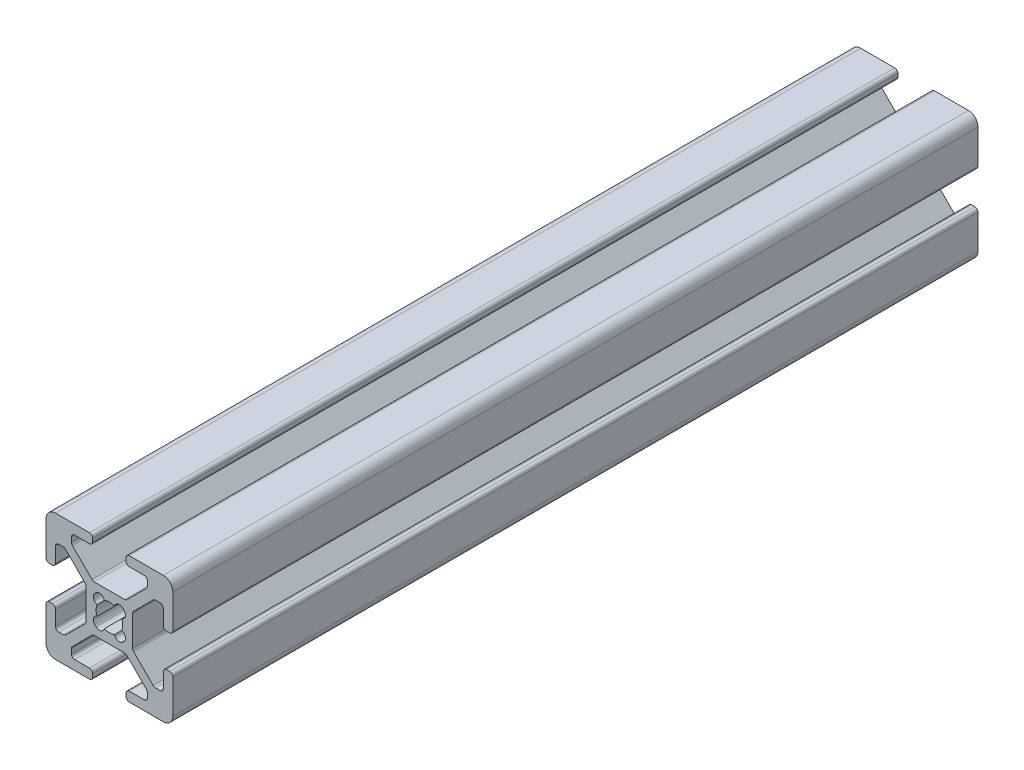
from build123d import *

# Parameters (mm, degrees)
BOSS_EXTRUDE1_DEPTH = 127


with BuildPart() as part:
    # Sketch1 → Boss-Extrude1 (new body)
    with BuildSketch(Plane(origin=(0, 0, -4000), x_dir=(-1, 0, 0), z_dir=(0, 0, -1))):
        with BuildLine():
            Line((10, -8.5), (10, -3.138))
            ThreePointArc((10, -3.138), (9.851210245, -2.778789755), (9.492, -2.63))
            Line((9.492, -2.63), (9.008, -2.63))
            ThreePointArc((9.008, -2.63), (8.648789755, -2.778789755), (8.5, -3.138))
            Line((8.5, -3.138), (8.5, -5.487))
            ThreePointArc((8.5, -5.487), (8.351210245, -5.846210245), (7.992, -5.995))
            Line((7.992, -5.995), (7.26592049, -5.995))
            ThreePointArc((7.26592049, -5.995), (7.071517306, -5.956330803), (6.906710245, -5.846210245))
            Line((6.906710245, -5.846210245), (3.803789755, -2.743289755))
            ThreePointArc((3.803789755, -2.743289755), (3.693669197, -2.578482694), (3.655, -2.38407951))
            Line((3.655, -2.38407951), (3.655, 2.383759167))
            ThreePointArc((3.655, 2.383759167), (3.693669197, 2.57816235), (3.803789755, 2.742969412))
            Line((3.803789755, 2.742969412), (6.907030588, 5.846210245))
            ThreePointArc((6.907030588, 5.846210245), (7.07183765, 5.956330803), (7.266240833, 5.995))
            Line((7.266240833, 5.995), (7.992, 5.995))
            ThreePointArc((7.992, 5.995), (8.351210245, 5.846210245), (8.5, 5.487))
            Line((8.5, 5.487), (8.5, 3.138))
            ThreePointArc((8.5, 3.138), (8.648789755, 2.778789755), (9.008, 2.63))
            Line((9.008, 2.63), (9.492, 2.63))
            ThreePointArc((9.492, 2.63), (9.851210245, 2.778789755), (10, 3.138))
            Line((10, 3.138), (10, 8.5))
            ThreePointArc((10, 8.5), (9.560660172, 9.560660172), (8.5, 10))
            Line((8.5, 10), (3.138, 10))
            ThreePointArc((3.138, 10), (2.778789755, 9.851210245), (2.63, 9.492))
            Line((2.63, 9.492), (2.63, 9.008))
            ThreePointArc((2.63, 9.008), (2.778789755, 8.648789755), (3.138, 8.5))
            Line((3.138, 8.5), (5.487, 8.5))
            ThreePointArc((5.487, 8.5), (5.846210245, 8.351210245), (5.995, 7.992))
            Line((5.995, 7.992), (5.995, 7.26592049))
            ThreePointArc((5.995, 7.26592049), (5.956330803, 7.071517306), (5.846210245, 6.906710245))
            Line((5.846210245, 6.906710245), (2.743289755, 3.803789755))
            ThreePointArc((2.743289755, 3.803789755), (2.578482694, 3.693669197), (2.38407951, 3.655))
            Line((2.38407951, 3.655), (-2.383759167, 3.655))
            ThreePointArc((-2.383759167, 3.655), (-2.57816235, 3.693669197), (-2.742969412, 3.803789755))
            Line((-2.742969412, 3.803789755), (-5.846210245, 6.907030588))
            ThreePointArc((-5.846210245, 6.907030588), (-5.956330803, 7.07183765), (-5.995, 7.266240833))
            Line((-5.995, 7.266240833), (-5.995, 7.992))
            ThreePointArc((-5.995, 7.992), (-5.846210245, 8.351210245), (-5.487, 8.5))
            Line((-5.487, 8.5), (-3.138, 8.5))
            ThreePointArc((-3.138, 8.5), (-2.778789755, 8.648789755), (-2.63, 9.008))
            Line((-2.63, 9.008), (-2.63, 9.492))
            ThreePointArc((-2.63, 9.492), (-2.778789755, 9.851210245), (-3.138, 10))
            Line((-3.138, 10), (-8.5, 10))
            ThreePointArc((-8.5, 10), (-9.560660172, 9.560660172), (-10, 8.5))
            Line((-10, 8.5), (-10, 3.138))
            ThreePointArc((-10, 3.138), (-9.851210245, 2.778789755), (-9.492, 2.63))
            Line((-9.492, 2.63), (-9.008, 2.63))
            ThreePointArc((-9.008, 2.63), (-8.648789755, 2.778789755), (-8.5, 3.138))
            Line((-8.5, 3.138), (-8.5, 5.487))
            ThreePointArc((-8.5, 5.487), (-8.351210245, 5.846210245), (-7.992, 5.995))
            Line((-7.992, 5.995), (-7.26592049, 5.995))
            ThreePointArc((-7.26592049, 5.995), (-7.071517306, 5.956330803), (-6.906710245, 5.846210245))
            Line((-6.906710245, 5.846210245), (-3.803789755, 2.743289755))
            ThreePointArc((-3.803789755, 2.743289755), (-3.693669197, 2.578482694), (-3.655, 2.38407951))
            Line((-3.655, 2.38407951), (-3.655, -2.383759167))
            ThreePointArc((-3.655, -2.383759167), (-3.693669197, -2.57816235), (-3.803789755, -2.742969412))
            Line((-3.803789755, -2.742969412), (-6.907030588, -5.846210245))
            ThreePointArc((-6.907030588, -5.846210245), (-7.07183765, -5.956330803), (-7.266240833, -5.995))
            Line((-7.266240833, -5.995), (-7.992, -5.995))
            ThreePointArc((-7.992, -5.995), (-8.351210245, -5.846210245), (-8.5, -5.487))
            Line((-8.5, -5.487), (-8.5, -3.138))
            ThreePointArc((-8.5, -3.138), (-8.648789755, -2.778789755), (-9.008, -2.63))
            Line((-9.008, -2.63), (-9.492, -2.63))
            ThreePointArc((-9.492, -2.63), (-9.851210245, -2.778789755), (-10, -3.138))
            Line((-10, -3.138), (-10, -8.5))
            ThreePointArc((-10, -8.5), (-9.560660172, -9.560660172), (-8.5, -10))
            Line((-8.5, -10), (-3.138, -10))
            ThreePointArc((-3.138, -10), (-2.778789755, -9.851210245), (-2.63, -9.492))
            Line((-2.63, -9.492), (-2.63, -9.008))
            ThreePointArc((-2.63, -9.008), (-2.778789755, -8.648789755), (-3.138, -8.5))
            Line((-3.138, -8.5), (-5.487, -8.5))
            ThreePointArc((-5.487, -8.5), (-5.846210245, -8.351210245), (-5.995, -7.992))
            Line((-5.995, -7.992), (-5.995, -7.26592049))
            ThreePointArc((-5.995, -7.26592049), (-5.956330803, -7.071517306), (-5.846210245, -6.906710245))
            Line((-5.846210245, -6.906710245), (-2.743289755, -3.803789755))
            ThreePointArc((-2.743289755, -3.803789755), (-2.578482694, -3.693669197), (-2.38407951, -3.655))
            Line((-2.38407951, -3.655), (2.383759167, -3.655))
            ThreePointArc((2.383759167, -3.655), (2.57816235, -3.693669197), (2.742969412, -3.803789755))
            Line((2.742969412, -3.803789755), (5.846210245, -6.907030588))
            ThreePointArc((5.846210245, -6.907030588), (5.956330803, -7.07183765), (5.995, -7.266240833))
            Line((5.995, -7.266240833), (5.995, -7.992))
            ThreePointArc((5.995, -7.992), (5.846210245, -8.351210245), (5.487, -8.5))
            Line((5.487, -8.5), (3.138, -8.5))
            ThreePointArc((3.138, -8.5), (2.778789755, -8.648789755), (2.63, -9.008))
            Line((2.63, -9.008), (2.63, -9.492))
            ThreePointArc((2.63, -9.492), (2.778789755, -9.851210245), (3.138, -10))
            Line((3.138, -10), (8.5, -10))
            ThreePointArc((8.5, -10), (9.560660172, -9.560660172), (10, -8.5))
        make_face()
        with BuildLine():
            Line((2.304493037, -2.124493037), (2.124493037, -2.304493037))
            ThreePointArc((2.124493037, -2.304493037), (1.35638567, -2.506016078), (0.803729988, -1.935777391))
            ThreePointArc((0.803729988, -1.935777391), (0, -2.096), (-0.803729988, -1.935777391))
            ThreePointArc((-0.803729988, -1.935777391), (-1.35638567, -2.506016078), (-2.124493037, -2.304493037))
            Line((-2.124493037, -2.304493037), (-2.304493037, -2.124493037))
            ThreePointArc((-2.304493037, -2.124493037), (-2.506016078, -1.35638567), (-1.935777391, -0.803729988))
            ThreePointArc((-1.935777391, -0.803729988), (-2.096, 0), (-1.935777391, 0.803729988))
            ThreePointArc((-1.935777391, 0.803729988), (-2.506016078, 1.35638567), (-2.304493037, 2.124493037))
            Line((-2.304493037, 2.124493037), (-2.124493037, 2.304493037))
            ThreePointArc((-2.124493037, 2.304493037), (-1.35638567, 2.506016078), (-0.803729988, 1.935777391))
            ThreePointArc((-0.803729988, 1.935777391), (0, 2.096), (0.803729988, 1.935777391))
            ThreePointArc((0.803729988, 1.935777391), (1.35638567, 2.506016078), (2.124493037, 2.304493037))
            Line((2.124493037, 2.304493037), (2.304493037, 2.124493037))
            ThreePointArc((2.304493037, 2.124493037), (2.506016078, 1.35638567), (1.935777391, 0.803729988))
            ThreePointArc((1.935777391, 0.803729988), (2.096, 0), (1.935777391, -0.803729988))
            ThreePointArc((1.935777391, -0.803729988), (2.506016078, -1.35638567), (2.304493037, -2.124493037))
        make_face(mode=Mode.SUBTRACT)
    extrude(amount=-BOSS_EXTRUDE1_DEPTH)


solid = part.part
